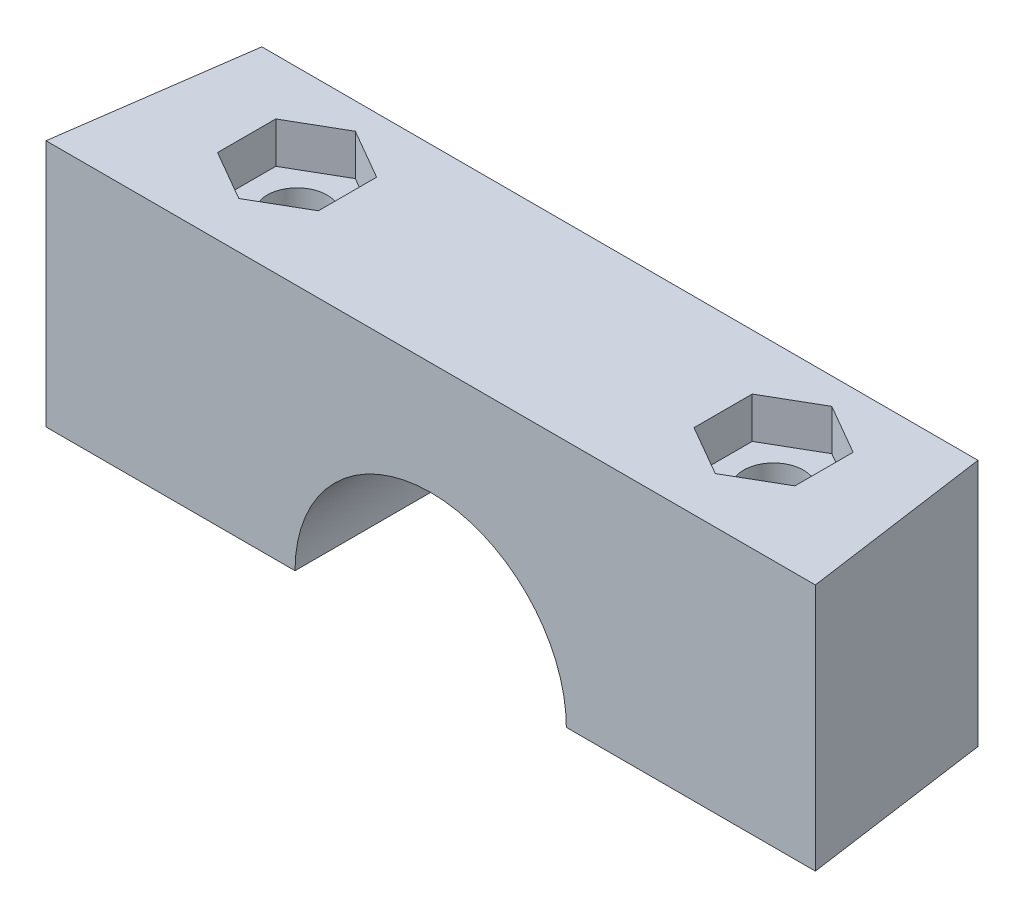
from build123d import *

# Parameters (mm, degrees)
BOSS_EXTRUDE3_DEPTH              = 14.5
SKETCH8_R                        = 7.935
CUT_EXTRUDE3_DEPTH               = 88
CUT_EXTRUDE9_DEPTH               = 2.4
F_39_0_13779528_DIAMETER_HOLE1_D = 3.500000112
CUT_EXTRUDE10_DEPTH              = 22.4
CUT_EXTRUDE11_DEPTH              = 2.4


with BuildPart() as part:
    # Sketch6 → Boss-Extrude3 (new body)
    with BuildSketch(Plane(origin=(0, 0, 0), x_dir=(1, 0, 0), z_dir=(0, 1, 0))):
        Polygon((-16.836914056, 5.783353512), (13.163085944, 5.783353512), (20.663085944, -47.581919406), (-24.336914056, -47.581919406), align=None)
    extrude(amount=BOSS_EXTRUDE3_DEPTH)

    # Sketch8 → Cut-Extrude3 (cut)
    with BuildSketch(Plane.XY.offset(47.581919406)):
        with Locations((-1.836914056, 0)):
            Circle(SKETCH8_R)
    extrude(amount=-CUT_EXTRUDE3_DEPTH, mode=Mode.SUBTRACT)

    # Sketch18 → Cut-Extrude9 (cut)
    with BuildSketch(Plane(origin=(0, 14.5, 0), x_dir=(1, 0, 0), z_dir=(0, 1, 0))):
        Polygon((-15.771819769, -44.868285994), (-12.821819769, -43.1651027), (-12.821819769, -39.758736112), (-15.771819769, -38.055552818), (-18.721819769, -39.758736112), (-18.721819769, -43.1651027), align=None)
        Polygon((12.097991657, -44.868285994), (15.047991657, -43.1651027), (15.047991657, -39.758736112), (12.097991657, -38.055552818), (9.147991657, -39.758736112), (9.147991657, -43.1651027), align=None)
        Polygon((11.389331688, -26.016021021), (14.389331688, -24.283970214), (14.389331688, -20.819868599), (11.389331688, -19.087817791), (8.389331688, -20.819868599), (8.389331688, -24.283970214), align=None)
        Polygon((-15.0631598, -26.016021021), (-12.0631598, -24.283970214), (-12.0631598, -20.819868599), (-15.0631598, -19.087817791), (-18.0631598, -20.819868599), (-18.0631598, -24.283970214), align=None)
    extrude(amount=-CUT_EXTRUDE9_DEPTH, mode=Mode.SUBTRACT)

    # #39 (0.13779528) Diameter Hole1 (through all)
    with Locations(Plane(origin=(-15.0631598, 14.5, 22.551919406), x_dir=(0, 0, 1), z_dir=(0, 1, 0))):
        with Locations((0, 0), (0, 26.452491488), (18.91, -0.708659969), (18.91, 27.161151457)):
            Hole(F_39_0_13779528_DIAMETER_HOLE1_D / 2)

    # Sketch22 → Cut-Extrude10 (cut)
    with BuildSketch(Plane(origin=(0, 14.5, 0), x_dir=(1, 0, 0), z_dir=(0, 1, 0))):
        Polygon((-22.781301734, -36.51316259), (19.107473622, -36.51316259), (13.163085944, 5.783353512), (-16.836914056, 5.783353512), align=None)
    extrude(amount=-CUT_EXTRUDE10_DEPTH, mode=Mode.SUBTRACT)

    # Sketch24 → Cut-Extrude11 (cut)
    with BuildSketch(Plane.XZ):
        Polygon((-15.771819769, 38.055552818), (-12.821819769, 39.758736112), (-12.821819769, 43.1651027), (-15.771819769, 44.868285994), (-18.721819769, 43.1651027), (-18.721819769, 39.758736112), align=None)
        Polygon((12.097991657, 38.055552818), (15.047991657, 39.758736112), (15.047991657, 43.1651027), (12.097991657, 44.868285994), (9.147991657, 43.1651027), (9.147991657, 39.758736112), align=None)
    extrude(amount=-CUT_EXTRUDE11_DEPTH, mode=Mode.SUBTRACT)


solid = part.part
